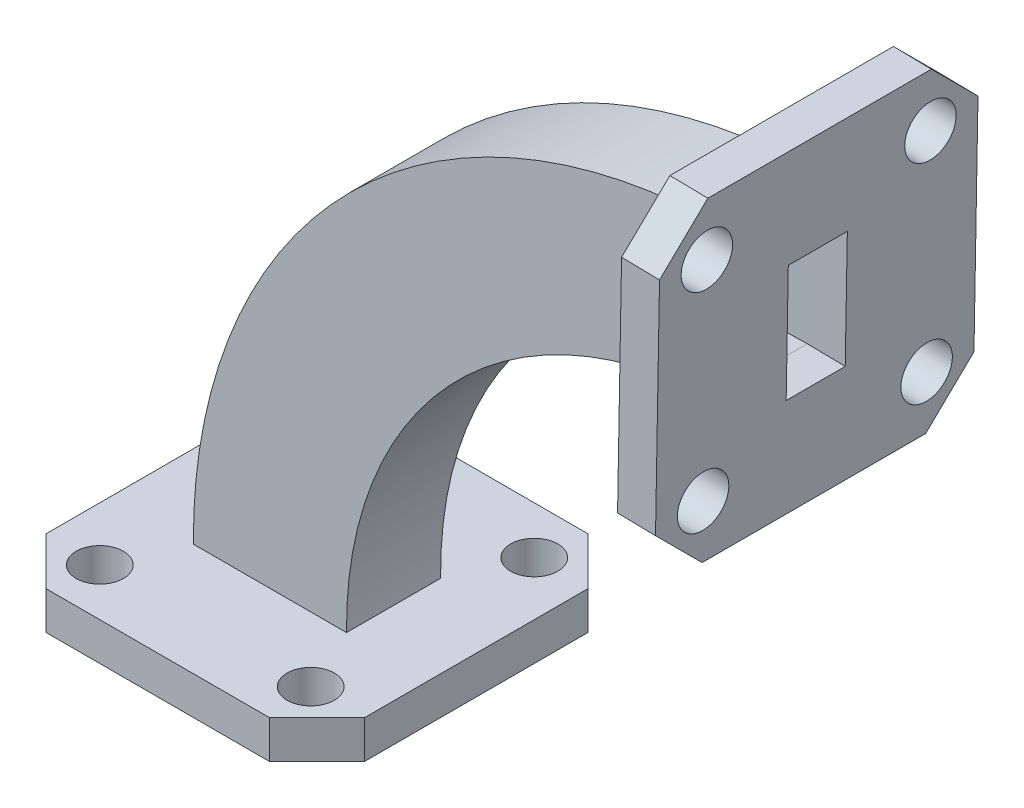
from build123d import *

# Parameters (mm, degrees)
SKETCH1_W           = 19.177
SKETCH1_H           = 19.177
BOSS_EXTRUDE1_DEPTH = 2.286
SKETCH2_R           = 1.4224
SKETCH2_W           = 7.112
SKETCH2_H           = 3.556
CUT_EXTRUDE1_DEPTH  = 2.286
SKETCH3_W           = 9.2202
SKETCH3_H           = 5.6642
SKETCH3_W_2         = 7.112
SKETCH3_H_2         = 3.556
SKETCH5_W           = 19.177
SKETCH5_H           = 19.177
SKETCH5_R           = 1.5494
SKETCH5_W_2         = 3.556
SKETCH5_H_2         = 7.112
BOSS_EXTRUDE2_DEPTH = 2.286
CHAMFER1_SIZE       = 2.8575


with BuildPart() as part:
    # Sketch1 → Boss-Extrude1 (new body)
    with BuildSketch(Plane(origin=(0, 0, 0), x_dir=(1, 0, 0), z_dir=(0, 1, 0))):
        Rectangle(SKETCH1_W, SKETCH1_H)
    extrude(amount=BOSS_EXTRUDE1_DEPTH)

    # Sketch2 → Cut-Extrude1 (cut)
    with BuildSketch(Plane(origin=(0, 2.286, 0), x_dir=(1, 0, 0), z_dir=(0, 1, 0))):
        with Locations((-6.35, 6.731)):
            Circle(SKETCH2_R)
        with Locations((6.35, 6.731)):
            Circle(SKETCH2_R)
        with Locations((6.35, -6.731)):
            Circle(SKETCH2_R)
        with Locations((-6.35, -6.731)):
            Circle(SKETCH2_R)
        Rectangle(SKETCH2_W, SKETCH2_H)
    extrude(amount=-CUT_EXTRUDE1_DEPTH, mode=Mode.SUBTRACT)

    # Sweep1: sweep along a path in Sketch4
    with BuildLine(Plane.XY) as sweep1_path:
        ThreePointArc((4.6101, 2.286), (11.285803016, 18.770237549), (27.7241, 25.558277811))
    # Sketch3 → Sweep1 (sweep)
    with BuildSketch(Plane(origin=(0, 2.286, 0), x_dir=(1, 0, 0), z_dir=(0, 1, 0))):
        Rectangle(SKETCH3_W, SKETCH3_H)
        Rectangle(SKETCH3_W_2, SKETCH3_H_2, mode=Mode.SUBTRACT)
    sweep(path=sweep1_path.line)

    # Sketch5 → Boss-Extrude2 (add)
    with BuildSketch(Plane(origin=(27.255255403, -0.490558544, 0), x_dir=(0, 0, -1), z_dir=(0.999838063, -0.017995763, 0))):
        with Locations((0, 30.663155305)):
            Rectangle(SKETCH5_W, SKETCH5_H)
        with Locations((-6.731, 37.013155305)):
            Circle(SKETCH5_R, mode=Mode.SUBTRACT)
        with Locations((6.731, 37.013155305)):
            Circle(SKETCH5_R, mode=Mode.SUBTRACT)
        with Locations((-6.731, 24.313155305)):
            Circle(SKETCH5_R, mode=Mode.SUBTRACT)
        with Locations((6.731, 24.313155305)):
            Circle(SKETCH5_R, mode=Mode.SUBTRACT)
        with Locations((0, 30.663155305)):
            Rectangle(SKETCH5_W_2, SKETCH5_H_2, mode=Mode.SUBTRACT)
    extrude(amount=BOSS_EXTRUDE2_DEPTH)

    # Chamfer1
    chamfer1_edges = [part.edges().sort_by_distance(p)[0] for p in [
        (29.122429541, 39.734009377, 9.5885),
        (28.777324802, 20.56011484, 9.5885),
        (28.777324802, 20.56011484, -9.5885),
        (29.122429541, 39.734009377, -9.5885),
        (-9.5885, 1.143, -9.5885),
        (9.5885, 1.143, -9.5885),
        (9.5885, 1.143, 9.5885),
        (-9.5885, 1.143, 9.5885),
    ]]
    chamfer(chamfer1_edges, length=CHAMFER1_SIZE)


solid = part.part
